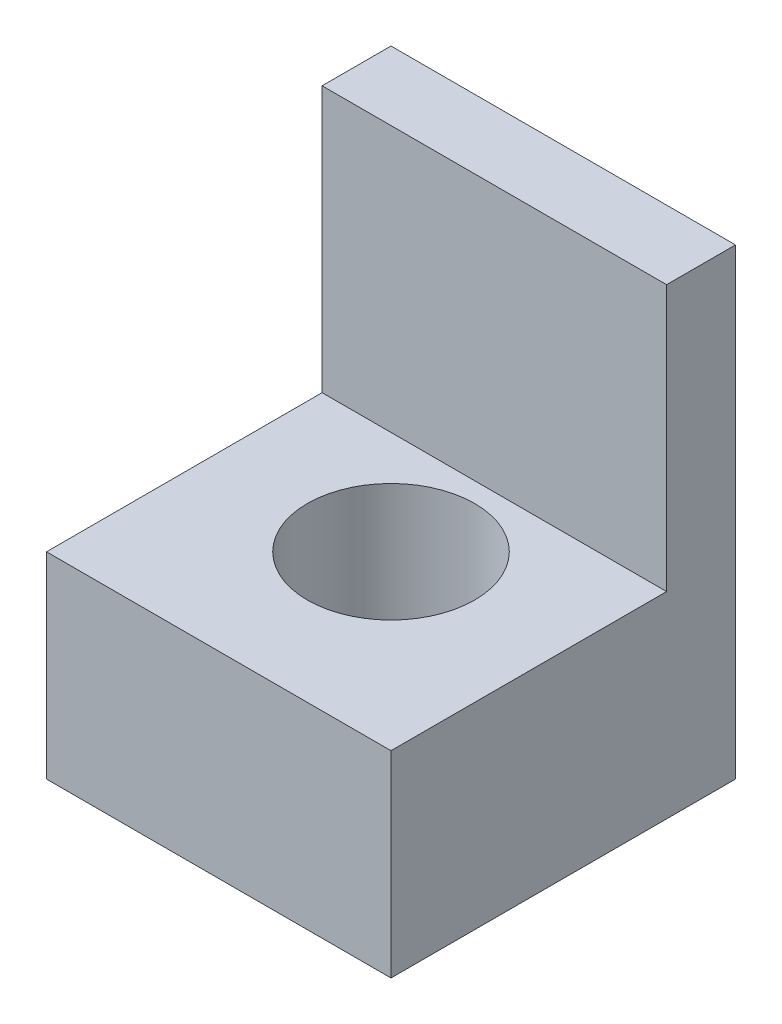
from build123d import *

# Parameters (mm, degrees)
SKETCH1_W             = 35
SKETCH1_H             = 35
BOSS_EXTRUDE1_DEPTH   = 20
SKETCH2_W             = 35
SKETCH2_H             = 7
BOSS_EXTRUDE2_DEPTH   = 27
SKETCH3_R             = 8.5
CUT_EXTRUDE1_DEPTH    = 20
M3_TAPPED_HOLE1_D     = 2.5
M3_TAPPED_HOLE1_DEPTH = 7.5
M3_TAPPED_HOLE1_TIP   = 0.751075774


with BuildPart() as part:
    # Sketch1 → Boss-Extrude1 (new body)
    with BuildSketch(Plane(origin=(0, 0, 0), x_dir=(1, 0, 0), z_dir=(0, 1, 0))):
        Rectangle(SKETCH1_W, SKETCH1_H)
    extrude(amount=BOSS_EXTRUDE1_DEPTH)

    # Sketch2 → Boss-Extrude2 (add)
    with BuildSketch(Plane(origin=(0, 20, 0), x_dir=(1, 0, 0), z_dir=(0, 1, 0))):
        with Locations((0, 14)):
            Rectangle(SKETCH2_W, SKETCH2_H)
    extrude(amount=BOSS_EXTRUDE2_DEPTH)

    # Sketch3 → Cut-Extrude1 (cut)
    with BuildSketch(Plane.XZ):
        Circle(SKETCH3_R)
    extrude(amount=-CUT_EXTRUDE1_DEPTH, mode=Mode.SUBTRACT)

    # M3 Tapped Hole1
    with Locations(Plane(origin=(0, 0, 0), x_dir=(-1, 0, 0), z_dir=(0, -1, 0))):
        with Locations((-12.5, 5.5), (12.5, 5.5), (12.5, -12.5), (-12.5, -12.5)):
            Hole(M3_TAPPED_HOLE1_D / 2, depth=M3_TAPPED_HOLE1_DEPTH)
            with Locations((0, 0, -(M3_TAPPED_HOLE1_DEPTH + M3_TAPPED_HOLE1_TIP / 2))):  # 118° drill point
                Cone(0, M3_TAPPED_HOLE1_D / 2, M3_TAPPED_HOLE1_TIP, mode=Mode.SUBTRACT)


solid = part.part
